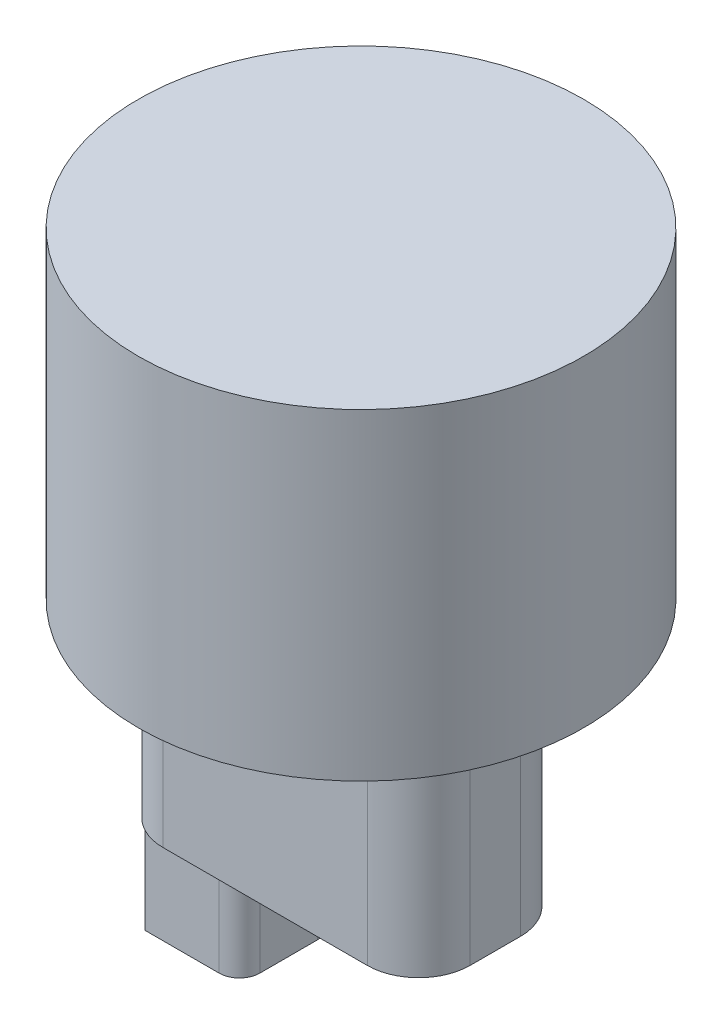
from build123d import *

# Parameters (mm, degrees)
SKETCH1_R           = 58
BOSS_EXTRUDE1_DEPTH = 83.82
BOSS_EXTRUDE2_DEPTH = 61.8
BOSS_EXTRUDE3_DEPTH = 90


with BuildPart() as part:
    # Sketch1 → Boss-Extrude1 (new body)
    with BuildSketch(Plane(origin=(0, 0, 0), x_dir=(1, 0, 0), z_dir=(0, 1, 0))):
        Circle(SKETCH1_R)
    extrude(amount=BOSS_EXTRUDE1_DEPTH)

    # Sketch2 → Boss-Extrude2 (add)
    with BuildSketch(Plane(origin=(0, 0, 0), x_dir=(1, 0, 0), z_dir=(0, 1, 0))):
        with BuildLine():
            Line((-45, -6.568854261), (-45, 6.568854261))
            ThreePointArc((-45, 6.568854261), (-41.075230868, 16.044085129), (-31.6, 19.968854261))
            Line((-31.6, 19.968854261), (21.6, 19.968854261))
            ThreePointArc((21.6, 19.968854261), (31.075230868, 16.044085129), (35, 6.568854261))
            Line((35, 6.568854261), (35, -6.568854261))
            ThreePointArc((35, -6.568854261), (31.075230868, -16.044085129), (21.6, -19.968854261))
            Line((21.6, -19.968854261), (-31.6, -19.968854261))
            ThreePointArc((-31.6, -19.968854261), (-41.075230868, -16.044085129), (-45, -6.568854261))
        make_face()
    extrude(amount=-BOSS_EXTRUDE2_DEPTH)

    # Sketch3 → Boss-Extrude3 (add)
    with BuildSketch(Plane(origin=(0, 0, 0), x_dir=(1, 0, 0), z_dir=(0, 1, 0))):
        with BuildLine():
            Line((-21.552493426, -4.8), (-21.552493426, 4.8))
            Line((-21.552493426, 4.8), (-21.552493426, 7.4))
            ThreePointArc((-21.552493426, 7.4), (-22.343305117, 9.309188309), (-24.252493426, 10.1))
            Line((-24.252493426, 10.1), (-26.852493426, 10.1))
            Line((-26.852493426, 10.1), (-44.526368777, 10.1))
            Line((-44.526368777, 10.1), (-43.463086562, 12.8))
            Line((-43.463086562, 12.8), (-24.152493426, 12.8))
            ThreePointArc((-24.152493426, 12.8), (-20.404827486, 11.24766594), (-18.852493426, 7.5))
            Line((-18.852493426, 7.5), (-18.852493426, -7.5))
            ThreePointArc((-18.852493426, -7.5), (-20.404827486, -11.24766594), (-24.152493426, -12.8))
            Line((-24.152493426, -12.8), (-40.189232196, -12.8))
            Line((-40.189232196, -12.8), (-43.463086562, -12.8))
            Line((-43.463086562, -12.8), (-44.526368777, -10.1))
            Line((-44.526368777, -10.1), (-26.852493426, -10.1))
            Line((-26.852493426, -10.1), (-24.252493426, -10.1))
            ThreePointArc((-24.252493426, -10.1), (-22.343305117, -9.309188309), (-21.552493426, -7.4))
            Line((-21.552493426, -7.4), (-21.552493426, -4.8))
        make_face()
    extrude(amount=-BOSS_EXTRUDE3_DEPTH)


solid = part.part
